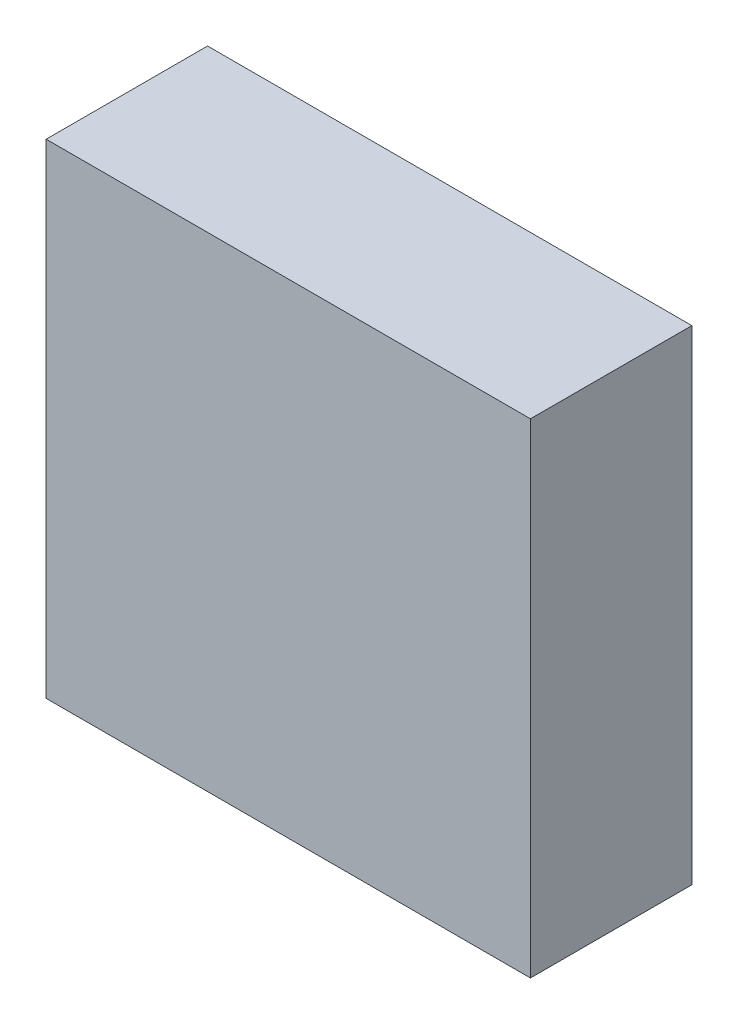
from build123d import *

# Parameters (mm, degrees)
SKETCH1_W           = 30
SKETCH1_H           = 30
BOSS_EXTRUDE1_DEPTH = 10


with BuildPart() as part:
    # Sketch1 → Boss-Extrude1 (new body)
    with BuildSketch(Plane.XY):
        Rectangle(SKETCH1_W, SKETCH1_H)
    extrude(amount=BOSS_EXTRUDE1_DEPTH)


solid = part.part
